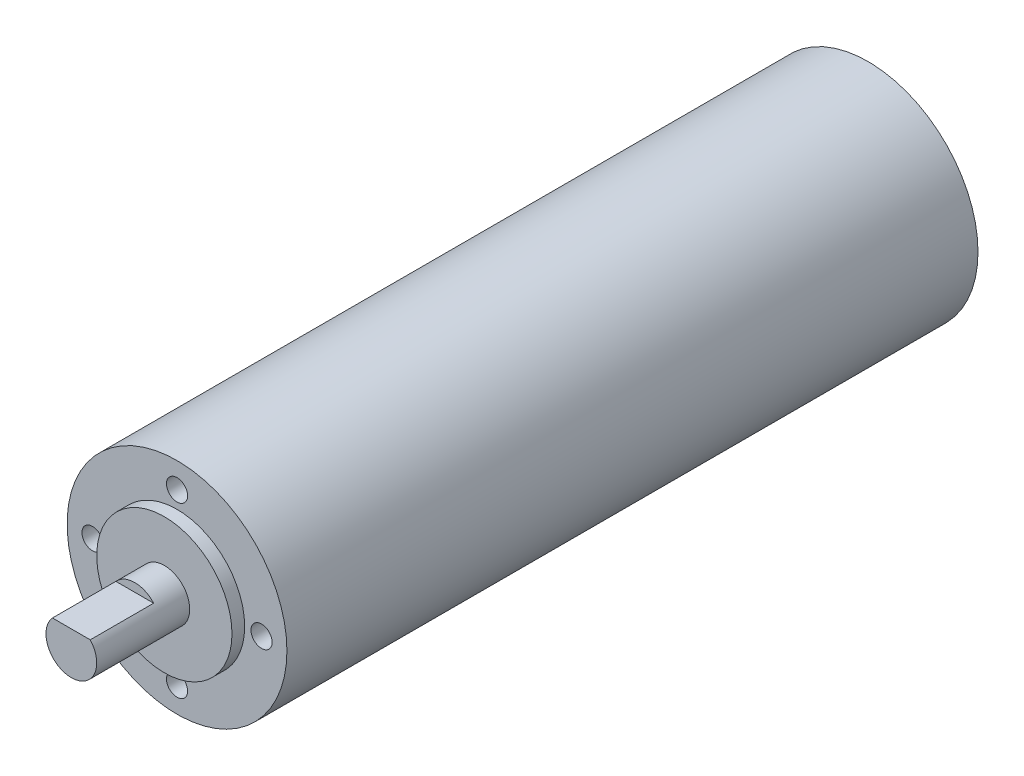
from build123d import *

# Parameters (mm, degrees)
SKETCH1_R           = 26
BOSS_EXTRUDE1_DEPTH = 163.5
SKETCH2_R           = 16
BOSS_EXTRUDE2_DEPTH = 3
SKETCH3_R           = 6
BOSS_EXTRUDE3_DEPTH = 22
CUT_EXTRUDE1_DEPTH  = 15
SKETCH6_R           = 2.5
CUT_EXTRUDE2_DEPTH  = 10


with BuildPart() as part:
    # Sketch1 → Boss-Extrude1 (new body)
    with BuildSketch(Plane.XY):
        Circle(SKETCH1_R)
    extrude(amount=BOSS_EXTRUDE1_DEPTH)

    # Sketch2 → Boss-Extrude2 (add)
    with BuildSketch(Plane.XY.offset(163.5)):
        Circle(SKETCH2_R)
    extrude(amount=BOSS_EXTRUDE2_DEPTH)

    # Sketch3 → Boss-Extrude3 (add)
    with BuildSketch(Plane.XY.offset(166.5)):
        Circle(SKETCH3_R)
    extrude(amount=BOSS_EXTRUDE3_DEPTH)

    # Sketch4 → Cut-Extrude1 (cut)
    with BuildSketch(Plane.XY.offset(188.5)):
        with BuildLine():
            ThreePointArc((0, 6), (-2.449489743, 5.477225575), (-4.472135955, 4))
            Line((-4.472135955, 4), (0, 4))
            Line((0, 4), (0, 6))
        make_face()
        with BuildLine():
            Line((0, 6), (0, 4))
            Line((0, 4), (4.472135955, 4))
            ThreePointArc((4.472135955, 4), (2.449489743, 5.477225575), (0, 6))
        make_face()
    extrude(amount=-CUT_EXTRUDE1_DEPTH, mode=Mode.SUBTRACT)

    # Sketch6 → Cut-Extrude2 (cut)
    with BuildSketch(Plane.XY.offset(163.5)):
        with Locations((0, 20)):
            Circle(SKETCH6_R)
        with Locations((20, 0)):
            Circle(SKETCH6_R)
        with Locations((0, -20)):
            Circle(SKETCH6_R)
        with Locations((-20, 0)):
            Circle(SKETCH6_R)
    extrude(amount=-CUT_EXTRUDE2_DEPTH, mode=Mode.SUBTRACT)


solid = part.part
